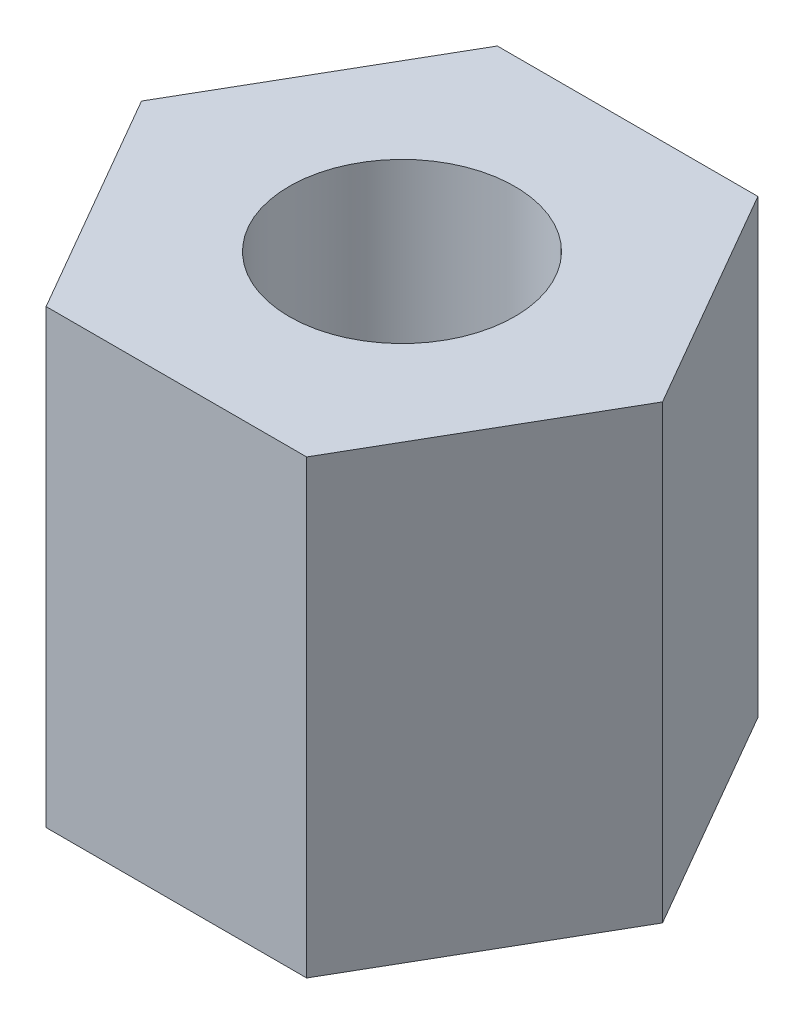
from build123d import *

# Parameters (mm, degrees)
SKETCH_1_R      = 1
EXTRUDE_1_DEPTH = 4


with BuildPart() as part:
    # 草图1 → 凸台-拉伸1 (new body)
    with BuildSketch(Plane(origin=(0, 0, 0), x_dir=(1, 0, 0), z_dir=(0, 1, 0))):
        Polygon((2.309401077, 0), (1.154700538, 2), (-1.154700538, 2), (-2.309401077, 0), (-1.154700538, -2), (1.154700538, -2), align=None)
        Circle(SKETCH_1_R, mode=Mode.SUBTRACT)
    extrude(amount=EXTRUDE_1_DEPTH)


solid = part.part
